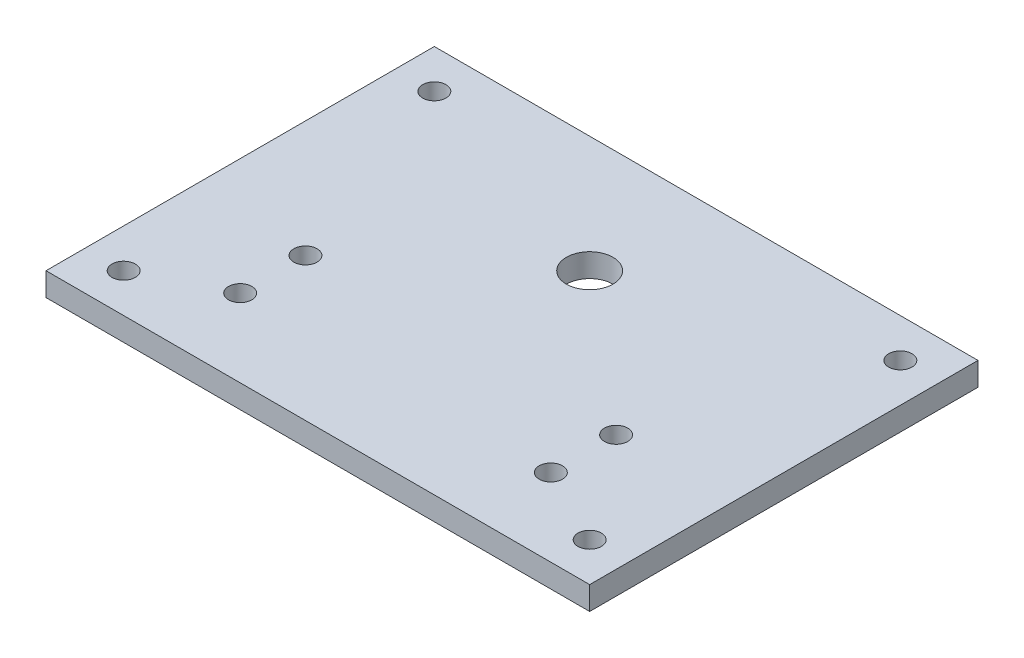
from build123d import *

# Parameters (mm, degrees)
SKIZZE3_W                            = 100
SKIZZE3_H                            = 6
AUFSATZ_LINEAR_AUSTRAGEN2_DEPTH      = 70
AUFSATZ_LINEAR_AUSTRAGEN2_DEPTH_BACK = 70
HOLES_R                              = 6
HOLES_R_2                            = 3
SCHNITT_LINEAR_AUSTRAGEN2_DEPTH      = 205
SKIZZE6_R                            = 3
SCHNITT_LINEAR_AUSTRAGEN3_DEPTH      = 205


with BuildPart() as part:
    # Skizze3 → Aufsatz-Linear austragen2 (new, two sides)
    with BuildSketch(Plane(origin=(0, 0, 0), x_dir=(0, 0, -1), z_dir=(1, 0, 0))) as aufsatz_linear_austragen2_sk:
        with Locations((-82.65, 202)):
            Rectangle(SKIZZE3_W, SKIZZE3_H)
    extrude(amount=AUFSATZ_LINEAR_AUSTRAGEN2_DEPTH)
    extrude(aufsatz_linear_austragen2_sk.sketch, amount=-AUFSATZ_LINEAR_AUSTRAGEN2_DEPTH_BACK)

    # Holes → Schnitt-Linear austragen2 (cut)
    with BuildSketch(Plane(origin=(0, 0, 0), x_dir=(1, 0, 0), z_dir=(0, 1, 0))):
        with Locations(Location((0, -62.65, 0), (0, 0, 90))):
            Circle(HOLES_R)
        with Locations(Location((-40, -112.65, 0), (0, 0, 90))):
            Circle(HOLES_R_2)
        with Locations(Location((-40, -95.839319437, 0), (0, 0, 90))):
            Circle(HOLES_R_2)
        with Locations(Location((40, -95.839319437, 0), (0, 0, 90))):
            Circle(HOLES_R_2)
        with Locations(Location((40, -112.65, 0), (0, 0, 90))):
            Circle(HOLES_R_2)
    extrude(amount=SCHNITT_LINEAR_AUSTRAGEN2_DEPTH, mode=Mode.SUBTRACT)

    # Skizze6 → Schnitt-Linear austragen3 (cut)
    with BuildSketch(Plane(origin=(0, 0, 0), x_dir=(1, 0, 0), z_dir=(0, 1, 0))):
        with Locations(Location((-60, -42.65, 0), (0, 0, 90))):
            Circle(SKIZZE6_R)
        with Locations(Location((60, -42.65, 0), (0, 0, 90))):
            Circle(SKIZZE6_R)
        with Locations(Location((60, -122.65, 0), (0, 0, 90))):
            Circle(SKIZZE6_R)
        with Locations(Location((-60, -122.65, 0), (0, 0, 90))):
            Circle(SKIZZE6_R)
    extrude(amount=SCHNITT_LINEAR_AUSTRAGEN3_DEPTH, mode=Mode.SUBTRACT)


solid = part.part
